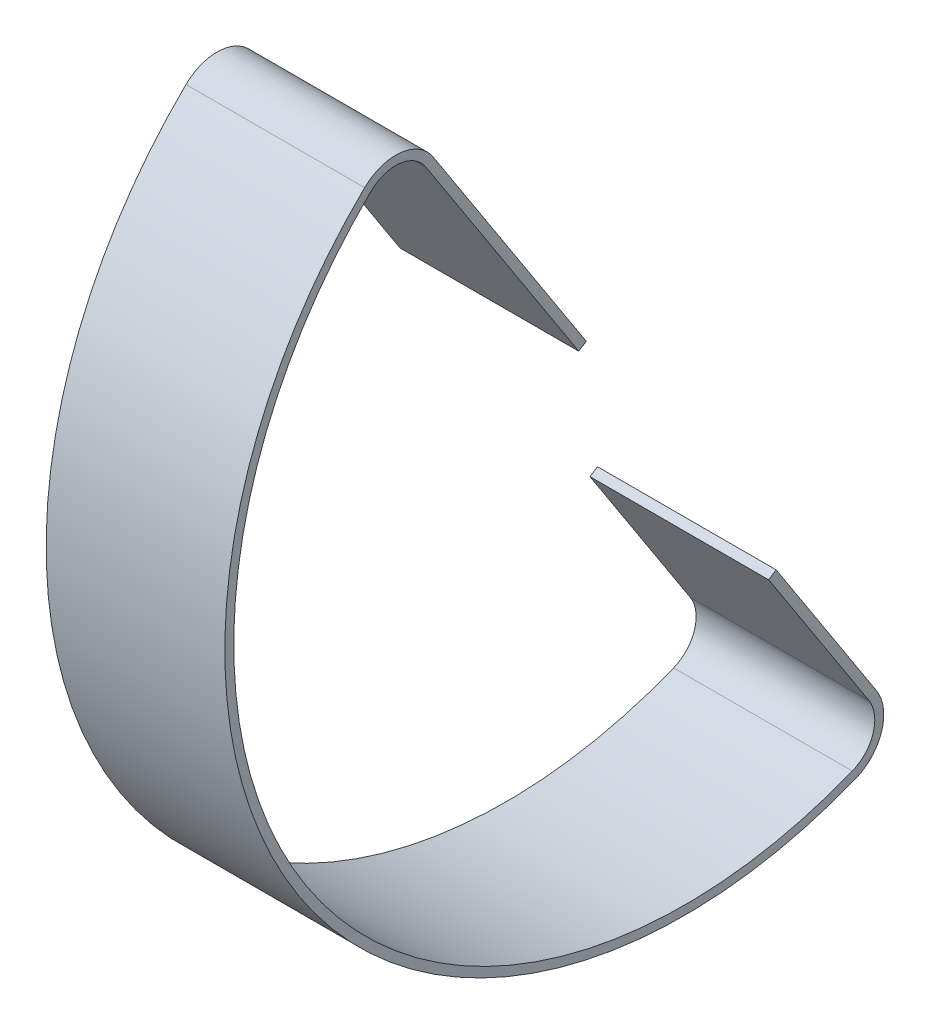
from build123d import *

# Parameters (mm, degrees)
EXTRUDE_THIN1_DEPTH = 25.4


with BuildPart() as part:
    # Sketch2 → Extrude-Thin1 (new body, symmetric)
    with BuildSketch(Plane(origin=(1981.2, 0, 0), x_dir=(0, 0, -1), z_dir=(1, 0, 0))):
        with BuildLine():
            Line((220.466063539, 151.267804305), (176.948936788, 218.39459013))
            ThreePointArc((176.948936788, 218.39459013), (167.722867176, 224.105285456), (157.452600901, 220.60470947))
            ThreePointArc((157.452600901, 220.60470947), (138.741359143, 55.545453365), (297.061605662, 5.252629462))
            ThreePointArc((297.061605662, 5.252629462), (304.44942683, 13.199484184), (303.002052812, 23.952972457))
            Line((303.002052812, 23.952972457), (274.455306754, 67.987389518))
            Line((274.455306754, 67.987389518), (272.32398896, 66.605693293))
            Line((272.32398896, 66.605693293), (300.870735018, 22.571276232))
            ThreePointArc((300.870735018, 22.571276232), (302.028634232, 13.968485614), (296.118377298, 7.611001836))
            ThreePointArc((296.118377298, 7.611001836), (140.872676937, 56.927149591), (159.220550284, 218.780989377))
            ThreePointArc((159.220550284, 218.780989377), (167.436763304, 221.581450166), (174.817618993, 217.012893905))
            Line((174.817618993, 217.012893905), (218.334745745, 149.88610808))
            Line((218.334745745, 149.88610808), (220.466063539, 151.267804305))
        make_face()
    extrude(amount=EXTRUDE_THIN1_DEPTH, both=True)


solid = part.part
